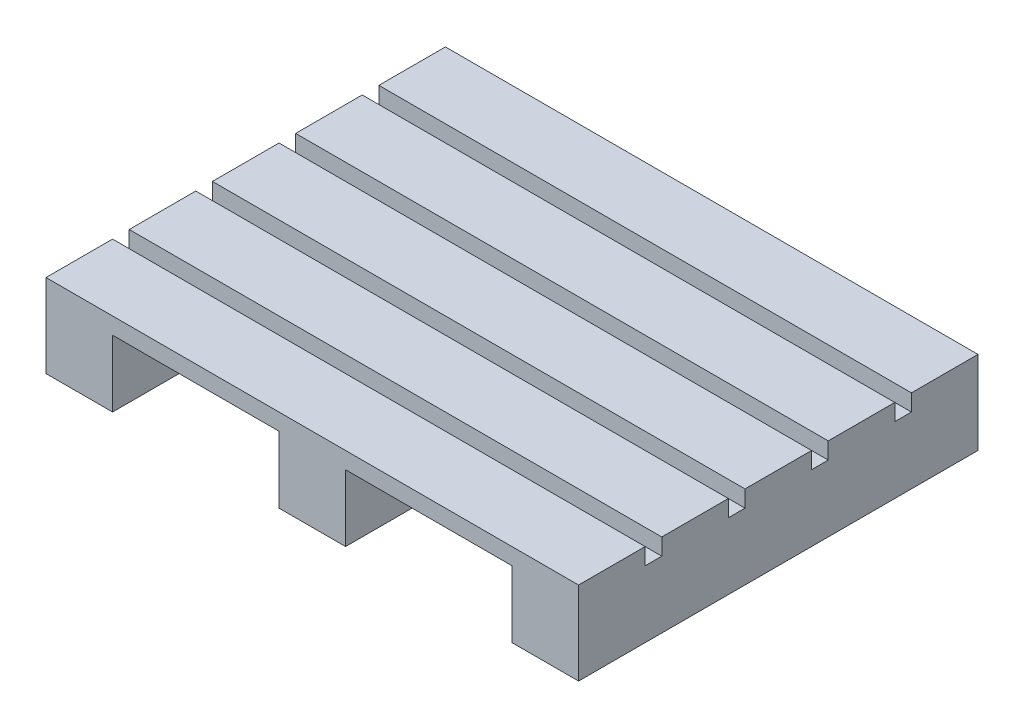
from build123d import *

# Parameters (mm, degrees)
CROQUIS1_W                = 10
CROQUIS1_H                = 60
SALIENTE_EXTRUIR1_DEPTH   = 10
SALIENTE_EXTRUIR1_2_DEPTH = 10
SALIENTE_EXTRUIR1_3_DEPTH = 10
CROQUIS2_W                = 80
CROQUIS2_H                = 10
SALIENTE_EXTRUIR2_DEPTH   = 2.5


with BuildPart() as part:
    # Croquis1 → Saliente-Extruir1 (new body)
    with BuildSketch(Plane(origin=(0, 0, 0), x_dir=(1, 0, 0), z_dir=(0, 1, 0))):
        with Locations((-51.849391859, -8.068789191)):
            Rectangle(CROQUIS1_W, CROQUIS1_H)
    extrude(amount=SALIENTE_EXTRUIR1_DEPTH)



with BuildPart() as body_2:
    # Croquis1 → Saliente-Extruir1 2 (new body)
    with BuildSketch(Plane(origin=(0, 0, 0), x_dir=(1, 0, 0), z_dir=(0, 1, 0))):
        with Locations((-16.849391859, -8.068789191)):
            Rectangle(CROQUIS1_W, CROQUIS1_H)
    extrude(amount=SALIENTE_EXTRUIR1_2_DEPTH)


with BuildPart() as body_3:
    # Croquis1 → Saliente-Extruir1 3 (new body)
    with BuildSketch(Plane(origin=(0, 0, 0), x_dir=(1, 0, 0), z_dir=(0, 1, 0))):
        with Locations((18.150608141, -8.068789191)):
            Rectangle(CROQUIS1_W, CROQUIS1_H)
    extrude(amount=SALIENTE_EXTRUIR1_3_DEPTH)


with BuildPart() as part_1:
    add(part.part)

    add(body_2.part)  # Saliente-Extruir2 merges body 2

    add(body_3.part)  # Saliente-Extruir2 merges body 3
    # Croquis2 → Saliente-Extruir2 (add)
    with BuildSketch(Plane(origin=(0, 10, 0), x_dir=(1, 0, 0), z_dir=(0, 1, 0))):
        with Locations((-16.849391859, -33.068789191)):
            Rectangle(CROQUIS2_W, CROQUIS2_H)
        with Locations((-16.849391859, 16.931210809)):
            Rectangle(CROQUIS2_W, CROQUIS2_H)
        with Locations((-16.849391859, 4.431210809)):
            Rectangle(CROQUIS2_W, CROQUIS2_H)
        with Locations((-16.849391859, -20.568789191)):
            Rectangle(CROQUIS2_W, CROQUIS2_H)
        with Locations((-16.849391859, -8.068789191)):
            Rectangle(CROQUIS2_W, CROQUIS2_H)
    extrude(amount=SALIENTE_EXTRUIR2_DEPTH)


solid = part_1.part
